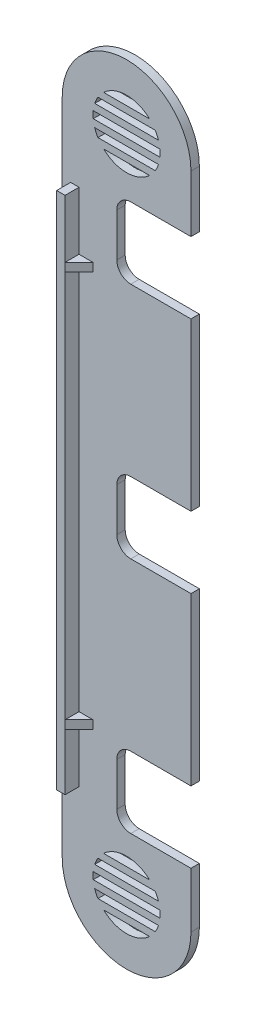
from build123d import *

# Parameters (mm, degrees)
BOSS_EXTRUDE1_DEPTH = 3
FILLET1_R           = 5
CUT_EXTRUDE1_DEPTH  = 3
SKETCH3_W           = 3
SKETCH3_H           = 185.5
BOSS_EXTRUDE2_DEPTH = 5
BOSS_EXTRUDE3_DEPTH = 3
BOSS_EXTRUDE4_DEPTH = 3


with BuildPart() as part:
    # Sketch1 → Boss-Extrude1 (new body)
    with BuildSketch(Plane.XY):
        with BuildLine():
            Line((-23.5, 139.962429423), (-23.5, 114.5))
            Line((-23.5, 114.5), (3, 114.5))
            Line((3, 114.5), (3, 54.962429423))
            Line((3, 54.962429423), (-23.5, 54.962429423))
            Line((-23.5, 54.962429423), (-23.5, 29.5))
            Line((-23.5, 29.5), (3, 29.5))
            Line((3, 29.5), (3, -30.037570577))
            Line((3, -30.037570577), (-23.5, -30.037570577))
            Line((-23.5, -30.037570577), (-23.5, -55.5))
            Line((-23.5, -55.5), (3, -55.5))
            Line((3, -55.5), (3, -75.25))
            ThreePointArc((3, -75.25), (-20, -98.25), (-43, -75.25))
            Line((-43, -75.25), (-43, 160.25))
            ThreePointArc((-43, 160.25), (-20, 183.25), (3, 160.25))
            Line((3, 160.25), (3, 139.962429423))
            Line((3, 139.962429423), (-23.5, 139.962429423))
        make_face()
    extrude(amount=BOSS_EXTRUDE1_DEPTH)

    # Fillet1
    fillet1_edges = [part.edges().sort_by_distance(p)[0] for p in [
        (-23.5, 139.962429423, 1.5),
        (-23.5, 114.5, 1.5),
        (-23.5, 54.962429423, 1.5),
        (-23.5, 29.5, 1.5),
        (-23.5, -30.037570577, 1.5),
        (-23.5, -55.5, 1.5),
    ]]
    fillet(fillet1_edges, radius=FILLET1_R)

    # Sketch2 → Cut-Extrude1 (cut)
    with BuildSketch(Plane.XY.offset(3)):
        with BuildLine():
            Line((-31.934718262, 161.5), (-8.065281738, 161.5))
            ThreePointArc((-8.065281738, 161.5), (-8, 160.25), (-8.065281738, 159))
            Line((-8.065281738, 159), (-31.934718262, 159))
            ThreePointArc((-31.934718262, 159), (-32, 160.25), (-31.934718262, 161.5))
        make_face()
        with BuildLine():
            Line((-31.399013115, 164), (-8.600986885, 164))
            ThreePointArc((-8.600986885, 164), (-9.106587826, 165.283246588), (-9.756099376, 166.5))
            Line((-9.756099376, 166.5), (-30.243900624, 166.5))
            ThreePointArc((-30.243900624, 166.5), (-30.893412174, 165.283246588), (-31.399013115, 164))
        make_face()
        with BuildLine():
            Line((-28.212033853, 169), (-11.787966147, 169))
            ThreePointArc((-11.787966147, 169), (-20, 172.25), (-28.212033853, 169))
        make_face()
        with BuildLine():
            Line((-28.212033853, 151.5), (-11.787966147, 151.5))
            ThreePointArc((-11.787966147, 151.5), (-20, 148.25), (-28.212033853, 151.5))
        make_face()
        with BuildLine():
            Line((-30.243900624, 154), (-9.756099376, 154))
            ThreePointArc((-9.756099376, 154), (-9.106587826, 155.216753412), (-8.600986885, 156.5))
            Line((-8.600986885, 156.5), (-31.399013115, 156.5))
            ThreePointArc((-31.399013115, 156.5), (-30.893412174, 155.216753412), (-30.243900624, 154))
        make_face()
        with BuildLine():
            Line((-31.399013115, -71.5), (-8.600986885, -71.5))
            ThreePointArc((-8.600986885, -71.5), (-9.106587826, -70.216753412), (-9.756099376, -69))
            Line((-9.756099376, -69), (-30.243900624, -69))
            ThreePointArc((-30.243900624, -69), (-30.893412174, -70.216753412), (-31.399013115, -71.5))
        make_face()
        with BuildLine():
            Line((-28.212033853, -66.5), (-11.787966147, -66.5))
            ThreePointArc((-11.787966147, -66.5), (-20, -63.25), (-28.212033853, -66.5))
        make_face()
        with BuildLine():
            Line((-31.934718262, -74), (-8.065281738, -74))
            ThreePointArc((-8.065281738, -74), (-8, -75.25), (-8.065281738, -76.5))
            Line((-8.065281738, -76.5), (-31.934718262, -76.5))
            ThreePointArc((-31.934718262, -76.5), (-32, -75.25), (-31.934718262, -74))
        make_face()
        with BuildLine():
            Line((-28.212033853, -84), (-11.787966147, -84))
            ThreePointArc((-11.787966147, -84), (-20, -87.25), (-28.212033853, -84))
        make_face()
        with BuildLine():
            Line((-30.243900624, -81.5), (-9.756099376, -81.5))
            ThreePointArc((-9.756099376, -81.5), (-9.106587826, -80.283246588), (-8.600986885, -79))
            Line((-8.600986885, -79), (-31.399013115, -79))
            ThreePointArc((-31.399013115, -79), (-30.893412174, -80.283246588), (-30.243900624, -81.5))
        make_face()
    extrude(amount=-CUT_EXTRUDE1_DEPTH, mode=Mode.SUBTRACT)

    # Sketch3 → Boss-Extrude2 (add)
    with BuildSketch(Plane.XY.offset(3)):
        with Locations((-38.5, 42.5)):
            Rectangle(SKETCH3_W, SKETCH3_H)
    extrude(amount=BOSS_EXTRUDE2_DEPTH)

    # Sketch4 → Boss-Extrude3 (add)
    with BuildSketch(Plane.XZ.offset(30.037570577)):
        Polygon((-37, 8), (-37, 3), (-32, 3), align=None)
    extrude(amount=-BOSS_EXTRUDE3_DEPTH)

    # Sketch5 → Boss-Extrude4 (add)
    with BuildSketch(Plane(origin=(0, 114.5, 0), x_dir=(1, 0, 0), z_dir=(0, 1, 0))):
        Polygon((-37, -8), (-32, -3), (-37, -3), align=None)
    extrude(amount=-BOSS_EXTRUDE4_DEPTH)


solid = part.part
